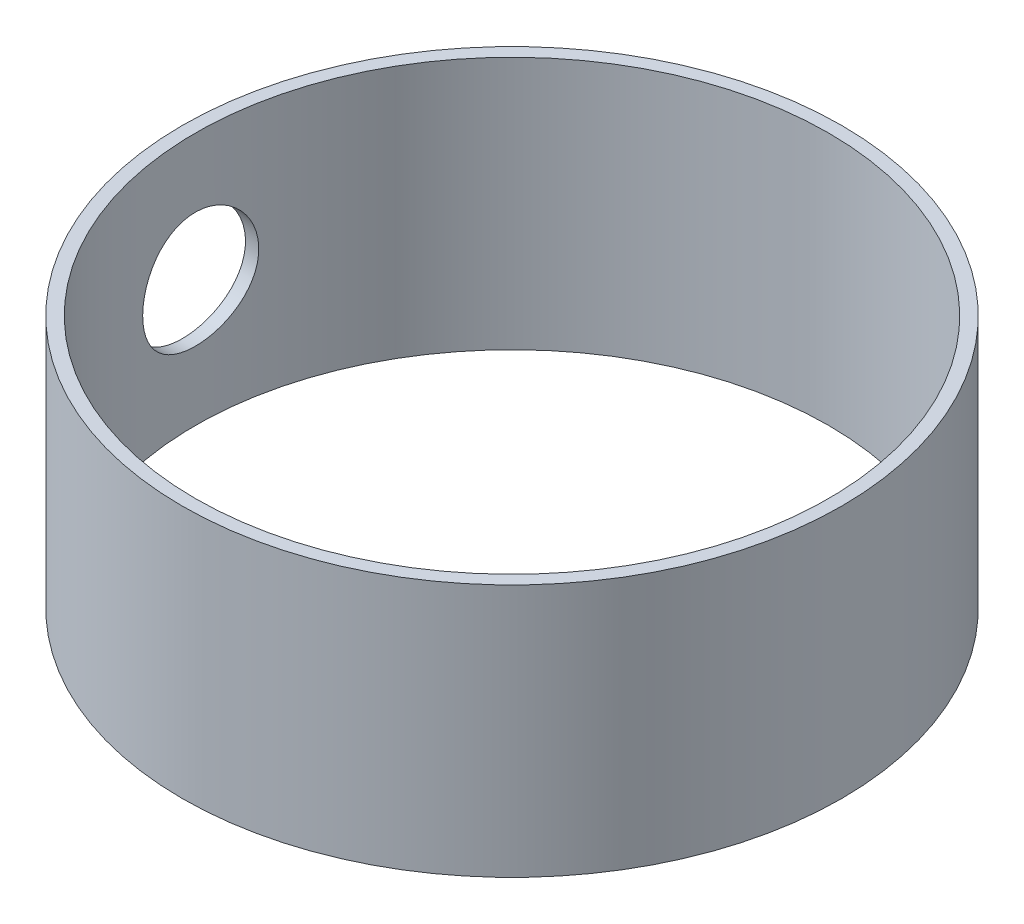
from build123d import *

# Parameters (mm, degrees)
SKETCH1_R           = 39.6748
SKETCH1_R_2         = 38.1
BOSS_EXTRUDE1_DEPTH = 15.24
SKETCH3_R           = 6.985
CUT_EXTRUDE1_DEPTH  = 6.35


with BuildPart() as part:
    # Sketch1 → Boss-Extrude1 (new body, symmetric)
    with BuildSketch(Plane(origin=(0, 0, 0), x_dir=(1, 0, 0), z_dir=(0, 1, 0))):
        Circle(SKETCH1_R)
        Circle(SKETCH1_R_2, mode=Mode.SUBTRACT)
    extrude(amount=BOSS_EXTRUDE1_DEPTH, both=True)

    # Sketch3 → Cut-Extrude1 (cut)
    with BuildSketch(Plane.ZY.offset(39.6748)):
        Circle(SKETCH3_R)
    extrude(amount=-CUT_EXTRUDE1_DEPTH, mode=Mode.SUBTRACT)


solid = part.part
